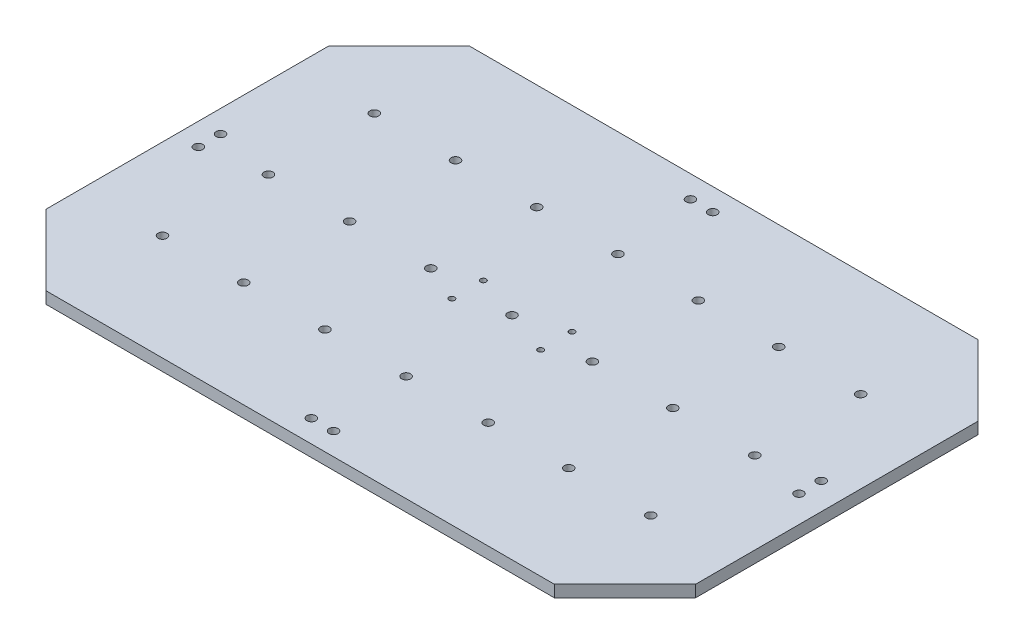
from build123d import *

# Parameters (mm, degrees)
MAIN_PLATE_DEPTH                = 5.3
F_4_0MM_CLEARANCE_DOWEL_HOLE1_D = 4
F_4_0MM_CLEARANCE_DOWEL_HOLE2_D = 4
F_3_0MM_PRESS_DOWEL_HOLE1_D     = 2.54
CUT_EXTRUDE1_DEPTH              = 6.3


with BuildPart() as part:
    # Sketch1 → Main Plate (new body)
    with BuildSketch(Plane(origin=(0, 0, 0), x_dir=(1, 0, 0), z_dir=(0, 1, 0))):
        Polygon((-146.05, -95.25), (146.05, -95.25), (146.05, -12.7), (146.05, 12.7), (146.05, 95.25), (-146.05, 95.25), (-146.05, 12.7), (-146.05, -12.7), align=None)
    extrude(amount=MAIN_PLATE_DEPTH)

    # Ø4.0mm Clearance Dowel Hole1 (through all)
    with Locations(Plane(origin=(0, 5.3, 0), x_dir=(1, 0, 0), z_dir=(0, 1, 0))):
        with Locations((109.17919222, -46.780829645), (72.308384441, -46.780829645), (36.5125, -47.202914823), (109.17919222, 0), (72.308384441, 0), (36.15419222, 0), (109.17919222, 47.625), (72.308384441, 47.625), (36.15419222, 47.625), (0, 47.625), (-36.5125, 47.625), (-73.025, 47.625), (-109.5375, 47.625), (-109.5375, 0), (-73.025, 0), (-36.5125, 0), (0, 0), (0, -47.625), (-36.5125, -47.625), (-73.025, -47.625), (-109.5375, -47.625)):
            Hole(F_4_0MM_CLEARANCE_DOWEL_HOLE1_D / 2)

    # Ø4.0mm Clearance Dowel Hole2 (through all)
    with Locations(Plane(origin=(0, 5.3, 0), x_dir=(1, 0, 0), z_dir=(0, 1, 0))):
        with Locations((5, -85.25), (-5, -85.25), (-136.05, -5), (-136.05, 5), (5, 85.25), (-5, 85.25), (134.05, -5), (134.05, 5)):
            Hole(F_4_0MM_CLEARANCE_DOWEL_HOLE2_D / 2)

    # Ø3.0mm Press Dowel Hole1 (through all)
    with Locations(Plane(origin=(0, 5.3, 0), x_dir=(1, 0, 0), z_dir=(0, 1, 0))):
        with Locations((-19.96, 7.07), (-19.96, -7.07), (19.96, 7.07), (19.96, -7.07)):
            Hole(F_3_0MM_PRESS_DOWEL_HOLE1_D / 2)

    # Sketch12 → Cut-Extrude1 (cut, through all)
    with BuildSketch(Plane(origin=(0, 5.3, 0), x_dir=(1, 0, 0), z_dir=(0, 1, 0))):
        Polygon((146.05, -63.5), (114.3, -95.25), (146.05, -95.25), align=None)
        Polygon((-114.3, -95.25), (-146.05, -63.5), (-146.05, -95.25), align=None)
        Polygon((-146.05, 95.25), (-146.05, 63.5), (-114.3, 95.25), align=None)
        Polygon((146.05, 95.25), (114.3, 95.25), (146.05, 63.5), align=None)
    extrude(amount=-CUT_EXTRUDE1_DEPTH, mode=Mode.SUBTRACT)


solid = part.part
